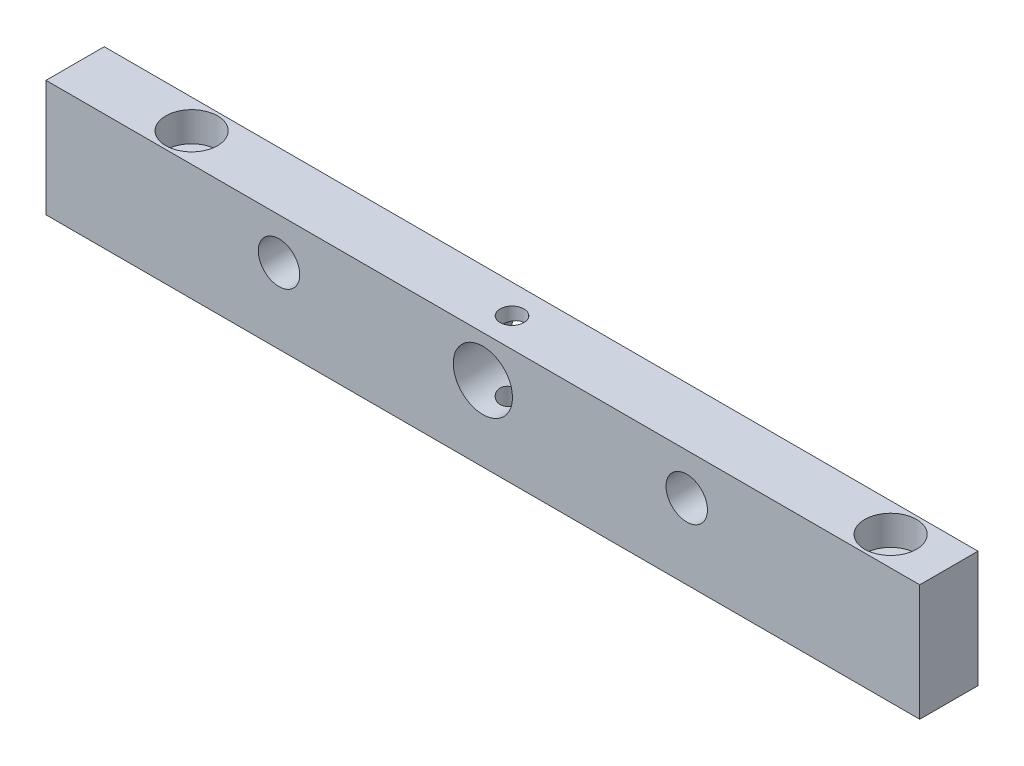
from build123d import *

# Parameters (mm, degrees)
SKETCH1_W                                        = 187.5
SKETCH1_H                                        = 12.5
BOSS_EXTRUDE1_DEPTH                              = 25
CBORE_FOR_1_4_SOCKET_HEAD_CAP_SCREW1_D           = 6.7564
CBORE_FOR_1_4_SOCKET_HEAD_CAP_SCREW1_CBORE_D     = 11.1125
CBORE_FOR_1_4_SOCKET_HEAD_CAP_SCREW1_CBORE_DEPTH = 6.35
CUT_EXTRUDE1_REACH                               = 176.672
SKETCH4_R                                        = 4.445
SKETCH4_R_2                                      = 6.35
F_1_4_20_TAPPED_HOLE1_D                          = 5.1054


with BuildPart() as part:
    # Sketch1 → Boss-Extrude1 (new body)
    with BuildSketch(Plane(origin=(0, 0, 0), x_dir=(1, 0, 0), z_dir=(0, 1, 0))):
        with Locations((78.671443618, -0.761090319)):
            Rectangle(SKETCH1_W, SKETCH1_H)
    extrude(amount=BOSS_EXTRUDE1_DEPTH)

    # CBORE for 1/4 Socket Head Cap Screw1 (through all)
    with Locations(Plane(origin=(9.921443618, 25, 0.761090319), x_dir=(0, 0, 1), z_dir=(0, 1, 0))):
        with Locations((0, 0), (0, 150.000000108)):
            CounterBoreHole(CBORE_FOR_1_4_SOCKET_HEAD_CAP_SCREW1_D / 2, CBORE_FOR_1_4_SOCKET_HEAD_CAP_SCREW1_CBORE_D / 2, CBORE_FOR_1_4_SOCKET_HEAD_CAP_SCREW1_CBORE_DEPTH)

    # Sketch4 → Cut-Extrude1 (cut, up to next)
    with BuildSketch(Plane(origin=(0, 0, -5.488909681), x_dir=(-1, 0, 0), z_dir=(0, 0, -1)), mode=Mode.PRIVATE) as cut_extrude1_sk1:
        with BuildLine():
            ThreePointArc((-30.476443618, 16.11), (-34.921443618, 20.555), (-39.366443618, 16.11))
            Line((-39.366443618, 16.11), (-30.476443618, 16.11))
        make_face()
    cut_extrude1_tool1 = extrude(cut_extrude1_sk1.sketch, amount=-CUT_EXTRUDE1_REACH, mode=Mode.PRIVATE) & part.part
    # Sketch4 → Cut-Extrude1 (cut, up to next)
    with BuildSketch(Plane(origin=(0, 0, -5.488909681), x_dir=(-1, 0, 0), z_dir=(0, 0, -1)), mode=Mode.PRIVATE) as cut_extrude1_sk2:
        with BuildLine():
            Line((-30.476443618, 16.11), (-39.366443618, 16.11))
            ThreePointArc((-39.366443618, 16.11), (-34.921443618, 11.665), (-30.476443618, 16.11))
        make_face()
    cut_extrude1_tool2 = extrude(cut_extrude1_sk2.sketch, amount=-CUT_EXTRUDE1_REACH, mode=Mode.PRIVATE) & part.part
    # Sketch4 → Cut-Extrude1 (cut, up to next)
    with BuildSketch(Plane(origin=(0, 0, -5.488909681), x_dir=(-1, 0, 0), z_dir=(0, 0, -1)), mode=Mode.PRIVATE) as cut_extrude1_sk3:
        with BuildLine():
            ThreePointArc((-30.476443618, 16.11), (-34.921443618, 20.555), (-39.366443618, 16.11))
            Line((-39.366443618, 16.11), (-30.476443618, 16.11))
        make_face()
    cut_extrude1_tool3 = extrude(cut_extrude1_sk3.sketch, amount=-CUT_EXTRUDE1_REACH, mode=Mode.PRIVATE) & part.part
    # Sketch4 → Cut-Extrude1 (cut, up to next)
    with BuildSketch(Plane(origin=(0, 0, -5.488909681), x_dir=(-1, 0, 0), z_dir=(0, 0, -1)), mode=Mode.PRIVATE) as cut_extrude1_sk4:
        with BuildLine():
            Line((-30.476443618, 16.11), (-39.366443618, 16.11))
            ThreePointArc((-39.366443618, 16.11), (-34.921443618, 11.665), (-30.476443618, 16.11))
        make_face()
    cut_extrude1_tool4 = extrude(cut_extrude1_sk4.sketch, amount=-CUT_EXTRUDE1_REACH, mode=Mode.PRIVATE) & part.part
    # Sketch4 → Cut-Extrude1 (cut, up to next)
    with BuildSketch(Plane(origin=(0, 0, -5.488909681), x_dir=(-1, 0, 0), z_dir=(0, 0, -1)), mode=Mode.PRIVATE) as cut_extrude1_sk5:
        with Locations((-122.421443618, 16.11)):
            Circle(SKETCH4_R)
    cut_extrude1_tool5 = extrude(cut_extrude1_sk5.sketch, amount=-CUT_EXTRUDE1_REACH, mode=Mode.PRIVATE) & part.part
    # Sketch4 → Cut-Extrude1 (cut, up to next)
    with BuildSketch(Plane(origin=(0, 0, -5.488909681), x_dir=(-1, 0, 0), z_dir=(0, 0, -1)), mode=Mode.PRIVATE) as cut_extrude1_sk6:
        with Locations((-78.671443618, 16.11)):
            Circle(SKETCH4_R_2)
    cut_extrude1_tool6 = extrude(cut_extrude1_sk6.sketch, amount=-CUT_EXTRUDE1_REACH, mode=Mode.PRIVATE) & part.part
    add(cut_extrude1_tool1.solids().sort_by_distance((34.921444, 17.996517, -5.48891))[0], mode=Mode.SUBTRACT)
    add(cut_extrude1_tool2.solids().sort_by_distance((34.921444, 14.223483, -5.48891))[0], mode=Mode.SUBTRACT)
    add(cut_extrude1_tool3.solids().sort_by_distance((34.921444, 17.996517, -5.48891))[0], mode=Mode.SUBTRACT)
    add(cut_extrude1_tool4.solids().sort_by_distance((34.921444, 14.223483, -5.48891))[0], mode=Mode.SUBTRACT)
    add(cut_extrude1_tool5.solids().sort_by_distance((122.421444, 16.11, -5.48891))[0], mode=Mode.SUBTRACT)
    add(cut_extrude1_tool6.solids().sort_by_distance((78.671444, 16.11, -5.48891))[0], mode=Mode.SUBTRACT)

    # 1/4-20 Tapped Hole1 (through all)
    with Locations(Plane(origin=(78.671443618, 25, 0.761090319), x_dir=(0, 0, 1), z_dir=(0, 1, 0))):
        with Locations((0, 0)):
            Hole(F_1_4_20_TAPPED_HOLE1_D / 2)


solid = part.part
